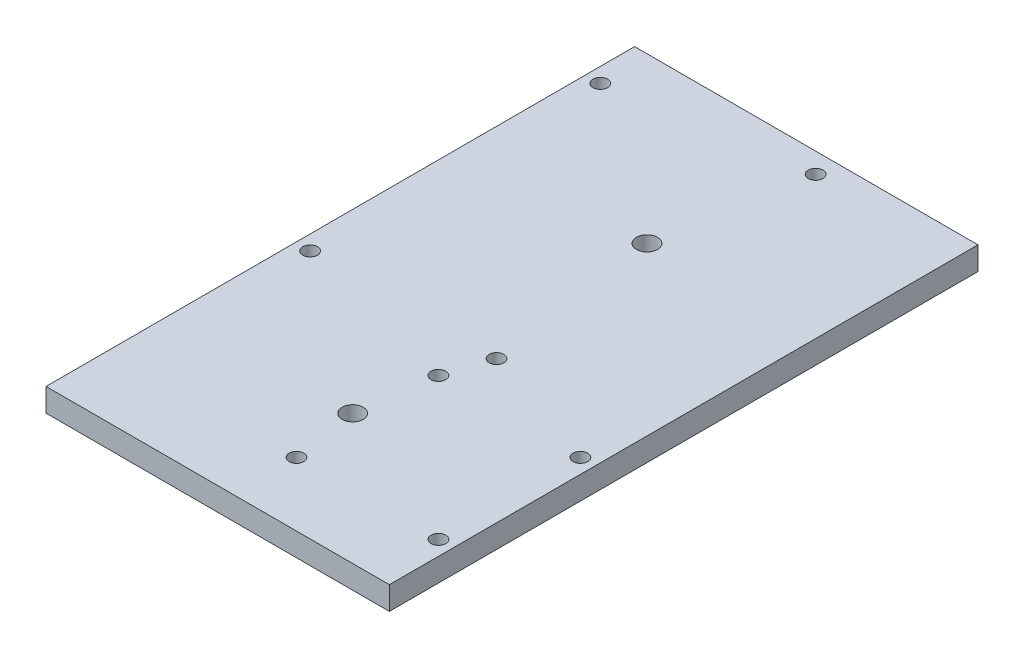
from build123d import *

# Parameters (mm, degrees)
SKETCH2_W               = 88.9
SKETCH2_H               = 152.4
BOSS_EXTRUDE1_DEPTH     = 5.9944
SKETCH3_R               = 1.905
CUT_EXTRUDE1_DEPTH      = 1
CUT_EXTRUDE1_DEPTH_BACK = 6.9944
SKETCH4_R               = 2.7305
CUT_EXTRUDE2_DEPTH      = 1
CUT_EXTRUDE2_DEPTH_BACK = 6.9944


with BuildPart() as part:
    # Sketch2 → Boss-Extrude1 (new body)
    with BuildSketch(Plane(origin=(0, 0, 0), x_dir=(1, 0, 0), z_dir=(0, 1, 0))):
        with Locations((44.45, 76.2)):
            Rectangle(SKETCH2_W, SKETCH2_H)
    extrude(amount=BOSS_EXTRUDE1_DEPTH)

    # Sketch3 → Cut-Extrude1 (cut, two sides)
    with BuildSketch(Plane(origin=(0, 5.9944, 0), x_dir=(1, 0, 0), z_dir=(0, 1, 0))) as cut_extrude1_sk:
        with Locations((52.07, 147.193)):
            Circle(SKETCH3_R)
        with Locations((3.81, 139.7)):
            Circle(SKETCH3_R)
        with Locations((3.81, 64.5668)):
            Circle(SKETCH3_R)
        with Locations((52.07, 64.5668)):
            Circle(SKETCH3_R)
        with Locations((48.3362, 53.2638)):
            Circle(SKETCH3_R)
        with Locations((85.09, 53.2638)):
            Circle(SKETCH3_R)
        with Locations((48.3362, 16.51)):
            Circle(SKETCH3_R)
        with Locations((85.09, 16.51)):
            Circle(SKETCH3_R)
    extrude(amount=CUT_EXTRUDE1_DEPTH, mode=Mode.SUBTRACT)
    extrude(cut_extrude1_sk.sketch, amount=-CUT_EXTRUDE1_DEPTH_BACK, mode=Mode.SUBTRACT)

    # Sketch4 → Cut-Extrude2 (cut, two sides)
    with BuildSketch(Plane(origin=(0, 5.9944, 0), x_dir=(1, 0, 0), z_dir=(0, 1, 0))) as cut_extrude2_sk:
        with Locations((45.72, 109.871331367)):
            Circle(SKETCH4_R)
        with Locations((45.72, 33.671331367)):
            Circle(SKETCH4_R)
    extrude(amount=CUT_EXTRUDE2_DEPTH, mode=Mode.SUBTRACT)
    extrude(cut_extrude2_sk.sketch, amount=-CUT_EXTRUDE2_DEPTH_BACK, mode=Mode.SUBTRACT)


solid = part.part
